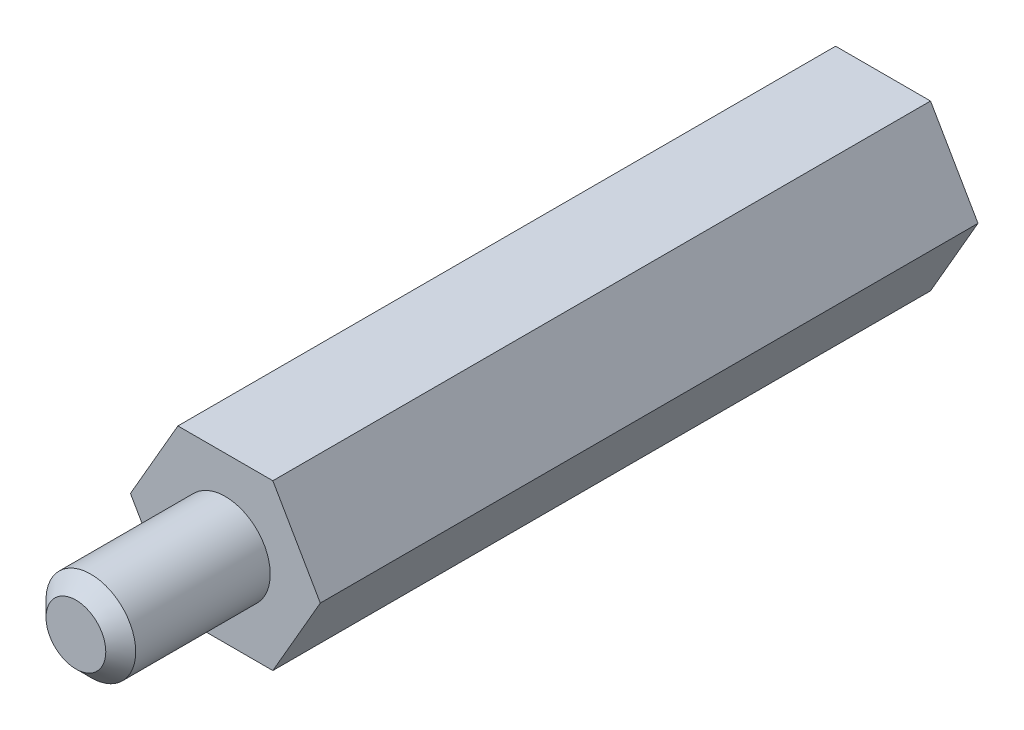
from build123d import *

# Parameters (mm, degrees)
EXTRUDE_1_DEPTH     = 22
SKETCH_2_R          = 1.5
EXTRUDE_2_DEPTH     = 5
CHAMFER_1_SIZE      = 0.5
SKETCH_3_R          = 1.5
CUT_EXTRUDE_1_DEPTH = 10


with BuildPart() as part:
    # 草图1 → 凸台-拉伸1 (new body)
    with BuildSketch(Plane.XY):
        Polygon((3.175426481, 0), (1.58771324, 2.75), (-1.58771324, 2.75), (-3.175426481, 0), (-1.58771324, -2.75), (1.58771324, -2.75), align=None)
    extrude(amount=EXTRUDE_1_DEPTH)

    # 草图2 → 凸台-拉伸2 (add)
    with BuildSketch(Plane.XY.offset(22)):
        Circle(SKETCH_2_R)
    extrude(amount=EXTRUDE_2_DEPTH)

    # 倒角1
    chamfer_1_edges = [part.edges().sort_by_distance(p)[0] for p in [
        (-1.5, 0, 27),
    ]]
    chamfer(chamfer_1_edges, length=CHAMFER_1_SIZE)

    # 草图3 → 切除-拉伸1 (cut)
    with BuildSketch(Plane(origin=(0, 0, 0), x_dir=(-1, 0, 0), z_dir=(0, 0, -1))):
        Circle(SKETCH_3_R)
    extrude(amount=-CUT_EXTRUDE_1_DEPTH, mode=Mode.SUBTRACT)


solid = part.part
